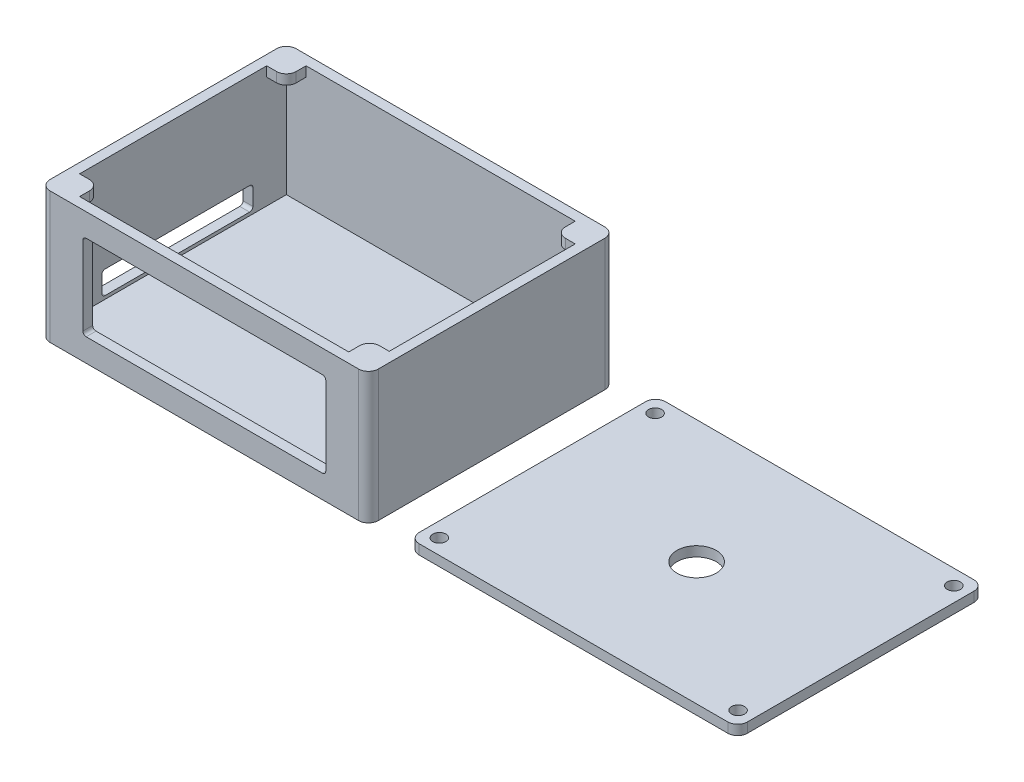
from build123d import *

# Parameters (mm, degrees)
IZIM2_W                     = 100
IZIM2_H                     = 75
Y_KSEKLIK_EKSTR_ZYON1_DEPTH = 40
IZIM4_W                     = 94
IZIM4_H                     = 69
KES_EKSTR_ZYON1_DEPTH       = 37
IZIM6_W                     = 74
IZIM6_H                     = 26
KES_EKSTR_ZYON2_DEPTH       = 218
IZIM7_W                     = 46
IZIM7_H                     = 7
KES_EKSTR_ZYON3_DEPTH       = 30
RADYUS1_R                   = 3
IZIM9_W                     = 6
IZIM9_H                     = 6
Y_KSEKLIK_EKSTR_ZYON2_DEPTH = 3
RADYUS2_R                   = 3
IZIM11_W                    = 6
IZIM11_H                    = 6
Y_KSEKLIK_EKSTR_ZYON3_DEPTH = 3
RADYUS3_R                   = 3
IZIM12_W                    = 6
IZIM12_H                    = 6
Y_KSEKLIK_EKSTR_ZYON4_DEPTH = 3
IZIM13_W                    = 6
IZIM13_H                    = 6.332172704
Y_KSEKLIK_EKSTR_ZYON5_DEPTH = 3
RADYUS4_R                   = 3
RADYUS5_R                   = 1
RADYUS7_R                   = 1
Y_KSEKLIK_EKSTR_ZYON6_DEPTH = 3
RADYUS10_R                  = 3
IZIM16_R                    = 6
KES_EKSTR_ZYON4_DEPTH       = 31
KES_EKSTR_ZYON4_DEPTH_BACK  = 34
IZIM17_R                    = 2
KES_EKSTR_ZYON5_DEPTH       = 20


with BuildPart() as part:
    # Çizim2 → Yükseklik-Ekstrüzyon1 (new body)
    with BuildSketch(Plane(origin=(0, 0, 0), x_dir=(1, 0, 0), z_dir=(0, 1, 0))):
        with Locations((4.482758621, -1.293103448)):
            Rectangle(IZIM2_W, IZIM2_H)
    extrude(amount=Y_KSEKLIK_EKSTR_ZYON1_DEPTH)

    # Çizim4 → Kes-Ekstrüzyon1 (cut)
    with BuildSketch(Plane(origin=(0, 40, 0), x_dir=(1, 0, 0), z_dir=(0, 1, 0))):
        with Locations((4.482758621, -1.293103448)):
            Rectangle(IZIM4_W, IZIM4_H)
    extrude(amount=-KES_EKSTR_ZYON1_DEPTH, mode=Mode.SUBTRACT)

    # Çizim6 → Kes-Ekstrüzyon2 (cut)
    with BuildSketch(Plane.XY):
        with Locations((4.482758621, 20)):
            Rectangle(IZIM6_W, IZIM6_H)
    extrude(amount=KES_EKSTR_ZYON2_DEPTH, mode=Mode.SUBTRACT)

    # Çizim7 → Kes-Ekstrüzyon3 (cut)
    with BuildSketch(Plane.ZY.offset(45.517241379)):
        with Locations((0, 7.5)):
            Rectangle(IZIM7_W, IZIM7_H)
    extrude(amount=-KES_EKSTR_ZYON3_DEPTH, mode=Mode.SUBTRACT)

    # Radyus1
    radyus1_edges = [part.edges().sort_by_distance(p)[0] for p in [
        (-45.517241379, 20, -36.206896552),
        (54.482758621, 20, -36.206896552),
        (54.482758621, 20, 38.793103448),
        (-45.517241379, 20, 38.793103448),
    ]]
    fillet(radyus1_edges, radius=RADYUS1_R)

    # Çizim9 → Yükseklik-Ekstrüzyon2 (add)
    with BuildSketch(Plane(origin=(0, 40, 0), x_dir=(1, 0, 0), z_dir=(0, 1, 0))):
        with Locations((-39.517241379, 30.206896552)):
            Rectangle(IZIM9_W, IZIM9_H)
    extrude(amount=-Y_KSEKLIK_EKSTR_ZYON2_DEPTH)

    # Radyus2
    radyus2_edges = [part.edges().sort_by_distance(p)[0] for p in [
        (-36.517241379, 38.5, -27.206896552),
    ]]
    fillet(radyus2_edges, radius=RADYUS2_R)

    # Çizim11 → Yükseklik-Ekstrüzyon3 (add)
    with BuildSketch(Plane(origin=(0, 40, 0), x_dir=(1, 0, 0), z_dir=(0, 1, 0))):
        with Locations((48.482758621, 30.206896552)):
            Rectangle(IZIM11_W, IZIM11_H)
    extrude(amount=-Y_KSEKLIK_EKSTR_ZYON3_DEPTH)

    # Radyus3
    radyus3_edges = [part.edges().sort_by_distance(p)[0] for p in [
        (45.482758621, 38.5, -27.206896552),
    ]]
    fillet(radyus3_edges, radius=RADYUS3_R)

    # Çizim12 → Yükseklik-Ekstrüzyon4 (add)
    with BuildSketch(Plane(origin=(0, 40, 0), x_dir=(1, 0, 0), z_dir=(0, 1, 0))):
        with Locations((-39.517241379, -32.793103448)):
            Rectangle(IZIM12_W, IZIM12_H)
    extrude(amount=-Y_KSEKLIK_EKSTR_ZYON4_DEPTH)

    # Çizim13 → Yükseklik-Ekstrüzyon5 (add)
    with BuildSketch(Plane(origin=(0, 40, 0), x_dir=(1, 0, 0), z_dir=(0, 1, 0))):
        with Locations((48.482758621, -32.627017096)):
            Rectangle(IZIM13_W, IZIM13_H)
    extrude(amount=-Y_KSEKLIK_EKSTR_ZYON5_DEPTH)

    # Radyus4
    radyus4_edges = [part.edges().sort_by_distance(p)[0] for p in [
        (-36.517241379, 38.5, 29.793103448),
        (45.482758621, 38.5, 29.460930744),
    ]]
    fillet(radyus4_edges, radius=RADYUS4_R)

    # Radyus5
    radyus5_edges = [part.edges().sort_by_distance(p)[0] for p in [
        (-44.017241379, 4, -23),
        (-44.017241379, 11, -23),
        (-44.017241379, 11, 23),
        (-44.017241379, 4, 23),
    ]]
    fillet(radyus5_edges, radius=RADYUS5_R)

    # Radyus7
    radyus7_edges = [part.edges().sort_by_distance(p)[0] for p in [
        (-32.517241379, 33, 37.293103448),
        (-32.517241379, 7, 37.293103448),
        (41.482758621, 7, 37.293103448),
        (41.482758621, 33, 37.293103448),
    ]]
    fillet(radyus7_edges, radius=RADYUS7_R)


with BuildPart() as body_2:
    # Çizim15 → Yükseklik-Ekstrüzyon6 (new body)
    with BuildSketch(Plane.XZ):
        Polygon((66.829636108, 35.664414978), (66.829636108, -36.335585022), (166.829636108, -36.335585022), (166.829636108, 38.664414978), (66.829636108, 38.664414978), align=None)
    extrude(amount=-Y_KSEKLIK_EKSTR_ZYON6_DEPTH)

    # Radyus10
    radyus10_edges = [body_2.edges().sort_by_distance(p)[0] for p in [
        (66.829636108, 1.5, 38.664414978),
        (166.829636108, 1.5, 38.664414978),
        (166.829636108, 1.5, -36.335585022),
        (66.829636108, 1.5, -36.335585022),
    ]]
    fillet(radyus10_edges, radius=RADYUS10_R)

    # Çizim16 → Kes-Ekstrüzyon4 (cut, two sides)
    with BuildSketch(Plane(origin=(0, 3, 0), x_dir=(1, 0, 0), z_dir=(0, 1, 0))) as kes_ekstr_zyon4_sk:
        with Locations((116.829636108, -1.164414978)):
            Circle(IZIM16_R)
    extrude(amount=KES_EKSTR_ZYON4_DEPTH, mode=Mode.SUBTRACT)
    extrude(kes_ekstr_zyon4_sk.sketch, amount=-KES_EKSTR_ZYON4_DEPTH_BACK, mode=Mode.SUBTRACT)

    # Çizim17 → Kes-Ekstrüzyon5 (cut)
    with BuildSketch(Plane(origin=(0, 3, 0), x_dir=(1, 0, 0), z_dir=(0, 1, 0))):
        with Locations((162.329636108, -34.035726507)):
            Circle(IZIM17_R)
        with Locations((71.329636108, -34.035726507)):
            Circle(IZIM17_R)
        with Locations((71.329636108, 31.706896552)):
            Circle(IZIM17_R)
        with Locations((162.329636108, 31.706896552)):
            Circle(IZIM17_R)
    extrude(amount=-KES_EKSTR_ZYON5_DEPTH, mode=Mode.SUBTRACT)


solid = Compound([part.part, body_2.part])
